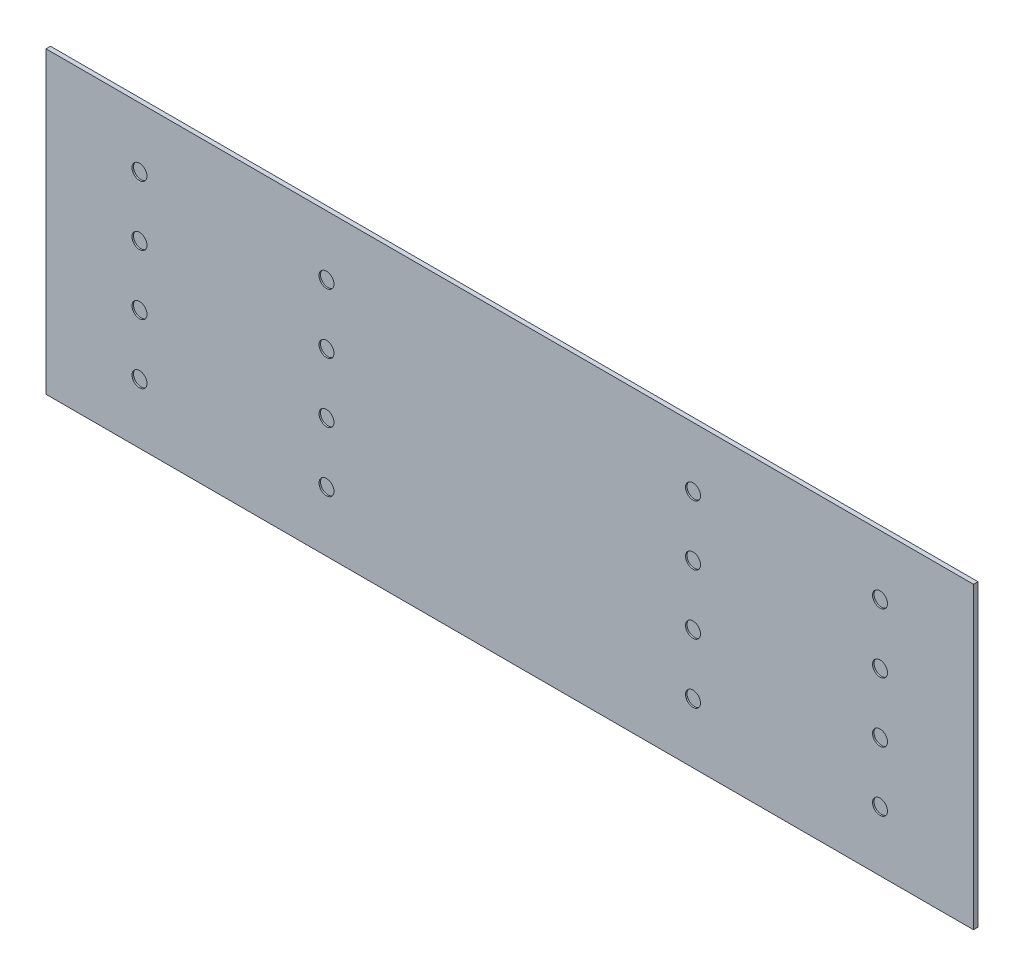
from build123d import *

# Parameters (mm, degrees)
SZKIC1_W                    = 62
SZKIC1_H                    = 20
DODANIE_WYCI_GNI_CIE1_DEPTH = 0.3
SZKIC2_R                    = 0.5
WYTNIJ_WYCI_GNI_CIE1_DEPTH  = 0.1


with BuildPart() as part:
    # Szkic1 → Dodanie-wyciągnięcie1 (new body)
    with BuildSketch(Plane.XY):
        Rectangle(SZKIC1_W, SZKIC1_H)
    extrude(amount=DODANIE_WYCI_GNI_CIE1_DEPTH)

    # Szkic2 → Wytnij-wyciągnięcie1 (cut)
    with BuildSketch(Plane.XY.offset(0.3)):
        with Locations((-24.75, 2)):
            Circle(SZKIC2_R)
        with Locations((-24.75, -2)):
            Circle(SZKIC2_R)
        with Locations((-12.25, 2)):
            Circle(SZKIC2_R)
        with Locations((-12.25, -2)):
            Circle(SZKIC2_R)
        with Locations((12.25, -2)):
            Circle(SZKIC2_R)
        with Locations((12.25, 2)):
            Circle(SZKIC2_R)
        with Locations((24.75, -2)):
            Circle(SZKIC2_R)
        with Locations((24.75, 2)):
            Circle(SZKIC2_R)
        with Locations((-24.75, 6)):
            Circle(SZKIC2_R)
        with Locations((-12.25, 6)):
            Circle(SZKIC2_R)
        with Locations((-24.75, -6)):
            Circle(SZKIC2_R)
        with Locations((-12.25, -6)):
            Circle(SZKIC2_R)
        with Locations((24.75, -6)):
            Circle(SZKIC2_R)
        with Locations((12.25, -6)):
            Circle(SZKIC2_R)
        with Locations((12.25, 6)):
            Circle(SZKIC2_R)
        with Locations((24.75, 6)):
            Circle(SZKIC2_R)
    extrude(amount=-WYTNIJ_WYCI_GNI_CIE1_DEPTH, mode=Mode.SUBTRACT)


solid = part.part
